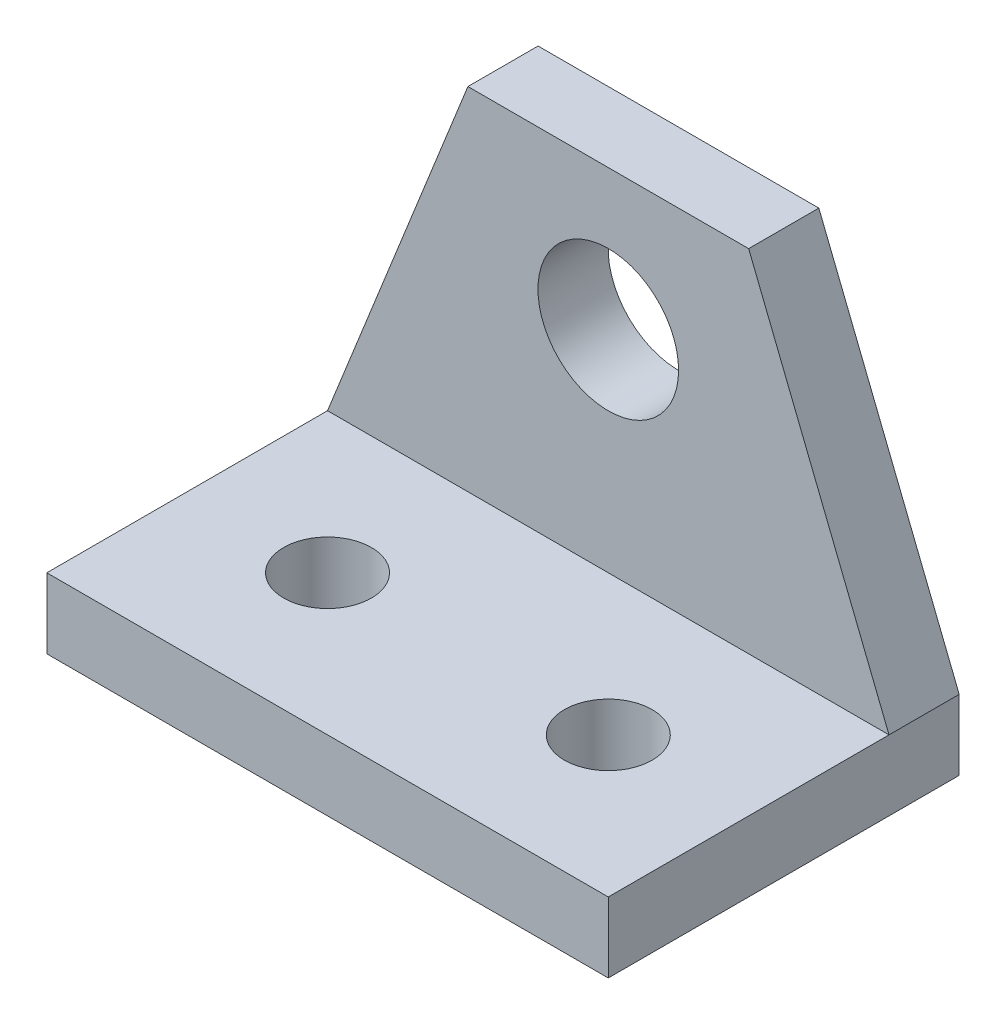
from build123d import *

# Parameters (mm, degrees)
SKETCH1_W           = 6.35
SKETCH1_H           = 31.75
BOSS_EXTRUDE1_DEPTH = 50.8
BASE_MOUNTS_REACH   = 8.35
SKETCH2_R           = 3.96875
PEDAL_HINGE_REACH   = 8.35
SKETCH3_R           = 6.3627


with BuildPart() as part:
    # Sketch1 → Boss-Extrude1 (new body)
    with BuildSketch(Plane(origin=(0, 0, 0), x_dir=(0, 0, -1), z_dir=(1, 0, 0))):
        Polygon((6.35, 6.35), (6.35, 0), (38.1, 0), (38.1, 6.35), (31.75, 6.35), align=None)
        with Locations((34.925, 22.225)):
            Rectangle(SKETCH1_W, SKETCH1_H)
    extrude(amount=BOSS_EXTRUDE1_DEPTH)

    # Sketch2 → Base Mounts (cut, up to next)
    with BuildSketch(Plane(origin=(0, 6.35, 0), x_dir=(1, 0, 0), z_dir=(0, 1, 0)), mode=Mode.PRIVATE) as base_mounts_sk1:
        with Locations((38.1, 19.05)):
            Circle(SKETCH2_R)
    base_mounts_tool1 = extrude(base_mounts_sk1.sketch, amount=-BASE_MOUNTS_REACH, mode=Mode.PRIVATE) & part.part
    add(base_mounts_tool1.solids().sort_by_distance((38.1, 6.35, -19.05))[0], mode=Mode.SUBTRACT)
    # Sketch2 → Base Mounts (cut, up to next)
    with BuildSketch(Plane(origin=(0, 6.35, 0), x_dir=(1, 0, 0), z_dir=(0, 1, 0)), mode=Mode.PRIVATE) as base_mounts_sk2:
        with Locations((12.7, 19.05)):
            Circle(SKETCH2_R)
    base_mounts_tool2 = extrude(base_mounts_sk2.sketch, amount=-BASE_MOUNTS_REACH, mode=Mode.PRIVATE) & part.part
    add(base_mounts_tool2.solids().sort_by_distance((12.7, 6.35, -19.05))[0], mode=Mode.SUBTRACT)

    # Sketch3 → Pedal Hinge (cut, up to next)
    with BuildSketch(Plane.XY.offset(-31.75), mode=Mode.PRIVATE) as pedal_hinge_sk1:
        with Locations((25.4, 25.4)):
            Circle(SKETCH3_R)
    pedal_hinge_tool1 = extrude(pedal_hinge_sk1.sketch, amount=-PEDAL_HINGE_REACH, mode=Mode.PRIVATE) & part.part
    add(pedal_hinge_tool1.solids().sort_by_distance((25.4, 25.4, -31.75))[0], mode=Mode.SUBTRACT)
    # Sketch3 → Pedal Hinge (cut, up to next)
    with BuildSketch(Plane.XY.offset(-31.75), mode=Mode.PRIVATE) as pedal_hinge_sk2:
        Polygon((50.8, 6.35), (50.8, 38.1), (38.1, 38.1), align=None)
    pedal_hinge_tool2 = extrude(pedal_hinge_sk2.sketch, amount=-PEDAL_HINGE_REACH, mode=Mode.PRIVATE) & part.part
    add(pedal_hinge_tool2.solids().sort_by_distance((46.566667, 27.516667, -31.75))[0], mode=Mode.SUBTRACT)
    # Sketch3 → Pedal Hinge (cut, up to next)
    with BuildSketch(Plane.XY.offset(-31.75), mode=Mode.PRIVATE) as pedal_hinge_sk3:
        Polygon((0, 6.35), (0, 38.1), (12.7, 38.1), align=None)
    pedal_hinge_tool3 = extrude(pedal_hinge_sk3.sketch, amount=-PEDAL_HINGE_REACH, mode=Mode.PRIVATE) & part.part
    add(pedal_hinge_tool3.solids().sort_by_distance((4.233333, 27.516667, -31.75))[0], mode=Mode.SUBTRACT)


solid = part.part
